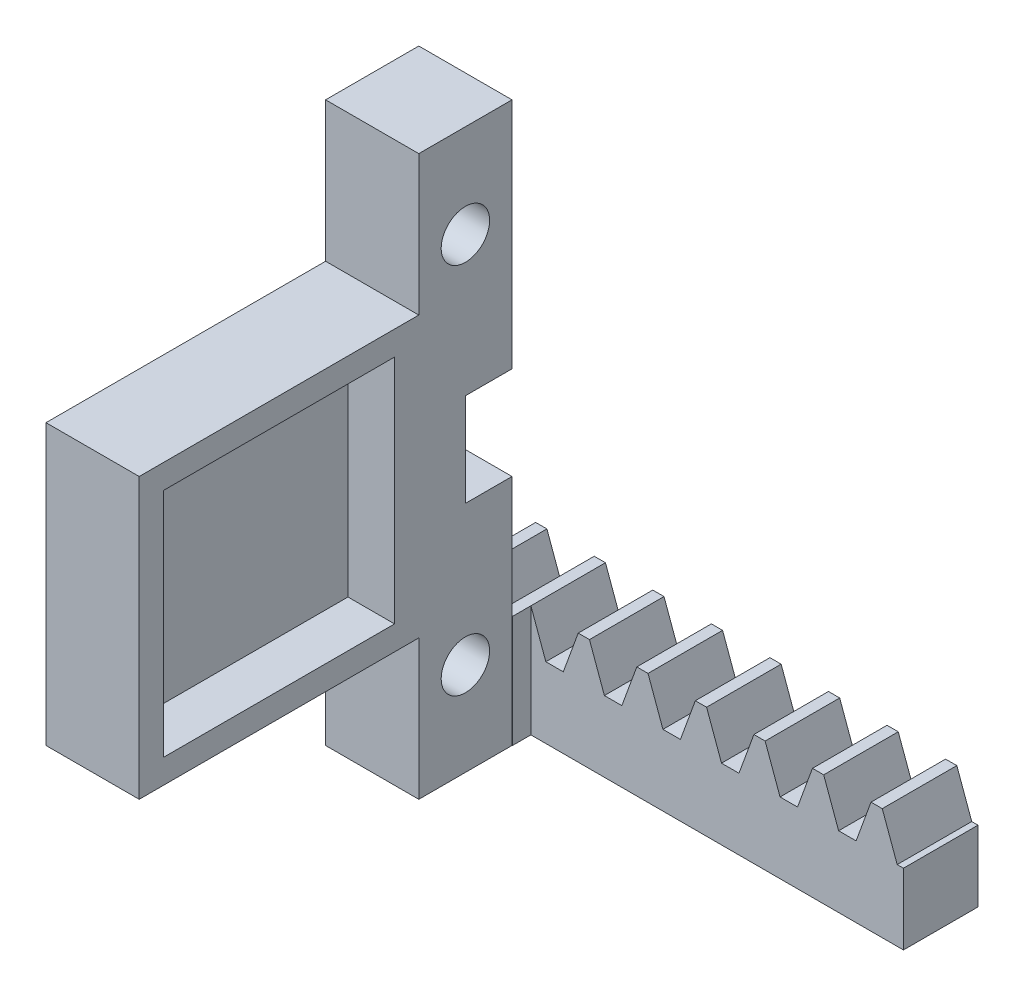
from build123d import *

# Parameters (mm, degrees)
BLANKSKE_W          = 31.75
BLANKSKE_H          = 7.62
BLANK_DEPTH         = 6.35
TOOTHCUTSIM_DEPTH   = 34.263334168
TEETHCUTS_COUNT     = 9
TEETHCUTS_PITCH     = 3.989822666
SKETCH1_W           = 6.35
SKETCH1_H           = 12.7
BOSS_EXTRUDE1_DEPTH = 6.35
SKETCH2_R           = 1.65
CUT_EXTRUDE1_DEPTH  = 6.35
SKETCH4_W           = 6.35
SKETCH4_H           = 19.05
BOSS_EXTRUDE3_DEPTH = 19.05
SKETCH6_W           = 6.35
SKETCH6_H           = 12.7
BOSS_EXTRUDE5_DEPTH = 6.35
SKETCH7_R           = 1.65
CUT_EXTRUDE2_DEPTH  = 6.35
SKETCH8_W           = 15.748
SKETCH8_H           = 15.748
CUT_EXTRUDE3_DEPTH  = 3.175
SKETCH11_W          = 6.35
SKETCH11_H          = 6.35
BOSS_EXTRUDE7_DEPTH = 12.7
SKETCH12_W          = 3.175
SKETCH12_H          = 6.35
CUT_EXTRUDE4_DEPTH  = 6.35
SKETCH13_W          = 25.382452533
SKETCH13_H          = 7.62
CUT_EXTRUDE5_DEPTH  = 1.27


with BuildPart() as part:
    # BlankSke → Blank (new body)
    with BuildSketch(Plane.XY):
        with Locations((15.875, 3.81)):
            Rectangle(BLANKSKE_W, BLANKSKE_H)
    extrude(amount=-BLANK_DEPTH)

    # TooCutSkeSim → ToothCutSim (cut, through all)
    with BuildSketch(Plane.XY):
        Polygon((0.595165029, 4.826), (-0.595165029, 4.826), (-1.621342708, 7.6454), (1.621342708, 7.6454), align=None)
    toothcutsim = extrude(amount=-TOOTHCUTSIM_DEPTH, mode=Mode.SUBTRACT)

    # TeethCuts: ToothCutSim ×9
    with Locations(*[(i * TEETHCUTS_PITCH, 0, 0) for i in range(1, TEETHCUTS_COUNT)]):
        add(toothcutsim, mode=Mode.SUBTRACT)

    # Sketch1 → Boss-Extrude1 (add)
    with BuildSketch(Plane.XY):
        with Locations((3.175, 6.35)):
            Rectangle(SKETCH1_W, SKETCH1_H)
    extrude(amount=BOSS_EXTRUDE1_DEPTH)

    # Sketch2 → Cut-Extrude1 (cut)
    with BuildSketch(Plane.ZY):
        with Locations((3.175, 6.35)):
            Circle(SKETCH2_R)
    extrude(amount=-CUT_EXTRUDE1_DEPTH, mode=Mode.SUBTRACT)

    # Sketch4 → Boss-Extrude3 (add)
    with BuildSketch(Plane.XY.offset(6.35)):
        with Locations((3.175, 19.05)):
            Rectangle(SKETCH4_W, SKETCH4_H)
    extrude(amount=BOSS_EXTRUDE3_DEPTH)

    # Sketch6 → Boss-Extrude5 (add)
    with BuildSketch(Plane(origin=(6.35, 0, 0), x_dir=(0, 0, -1), z_dir=(1, 0, 0))):
        with Locations((-3.175, 31.75)):
            Rectangle(SKETCH6_W, SKETCH6_H)
    extrude(amount=-BOSS_EXTRUDE5_DEPTH)

    # Sketch7 → Cut-Extrude2 (cut)
    with BuildSketch(Plane(origin=(6.35, 0, 0), x_dir=(0, 0, -1), z_dir=(1, 0, 0))):
        with Locations(Location((-3.175, 31.75, 0), (0, 0, 90))):
            Circle(SKETCH7_R)
    extrude(amount=-CUT_EXTRUDE2_DEPTH, mode=Mode.SUBTRACT)

    # Sketch8 → Cut-Extrude3 (cut)
    with BuildSketch(Plane(origin=(6.35, 0, 0), x_dir=(0, 0, -1), z_dir=(1, 0, 0))):
        with Locations((-15.875, 19.05)):
            Rectangle(SKETCH8_W, SKETCH8_H)
    extrude(amount=-CUT_EXTRUDE3_DEPTH, mode=Mode.SUBTRACT)

    # Sketch11 → Boss-Extrude7 (add)
    with BuildSketch(Plane(origin=(0, 12.7, 0), x_dir=(1, 0, 0), z_dir=(0, 1, 0))):
        with Locations((3.175, -3.175)):
            Rectangle(SKETCH11_W, SKETCH11_H)
    extrude(amount=BOSS_EXTRUDE7_DEPTH)

    # Sketch12 → Cut-Extrude4 (cut)
    with BuildSketch(Plane(origin=(6.35, 0, 0), x_dir=(0, 0, -1), z_dir=(1, 0, 0))):
        with Locations((-1.5875, 19.05)):
            Rectangle(SKETCH12_W, SKETCH12_H)
    extrude(amount=-CUT_EXTRUDE4_DEPTH, mode=Mode.SUBTRACT)

    # Sketch13 → Cut-Extrude5 (cut)
    with BuildSketch(Plane.XY):
        with Locations((19.058773734, 3.81)):
            Rectangle(SKETCH13_W, SKETCH13_H)
    extrude(amount=-CUT_EXTRUDE5_DEPTH, mode=Mode.SUBTRACT)


solid = part.part
